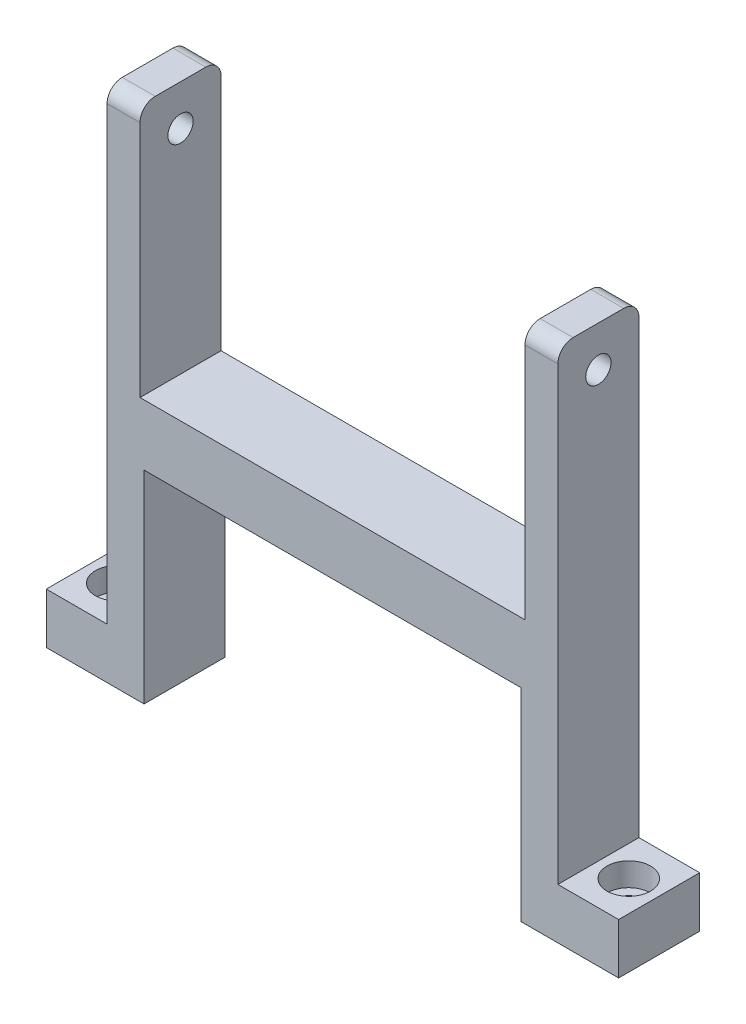
from build123d import *

# Parameters (mm, degrees)
SKETCH_1_W                = 44.5
SKETCH_1_H                = 51
EXTRUDE_1_DEPTH           = 8
SKETCH_2_W                = 38
SKETCH_2_H                = 25
CUT_EXTRUDE_1_DEPTH       = 9
MM_1_D                    = 2.5
FILLET_1_R                = 1.5
SKETCH_5_W                = 37.2
SKETCH_5_H                = 20
CUT_EXTRUDE_2_DEPTH       = 15
SKETCH_6_W                = 6
SKETCH_6_H                = 8
EXTRUDE_2_DEPTH           = 5
HOLE_WIZARD_2_D           = 2.4
HOLE_WIZARD_2_CBORE_D     = 4.3
HOLE_WIZARD_2_CBORE_DEPTH = 2.3


with BuildPart() as part:
    # 草图1 → 凸台-拉伸1 (new body)
    with BuildSketch(Plane.XY):
        Rectangle(SKETCH_1_W, SKETCH_1_H)
    extrude(amount=EXTRUDE_1_DEPTH)

    # 草图2 → 切除-拉伸1 (cut, through all)
    with BuildSketch(Plane.XY.offset(8)):
        with Locations((0, 13)):
            Rectangle(SKETCH_2_W, SKETCH_2_H)
    extrude(amount=-CUT_EXTRUDE_1_DEPTH, mode=Mode.SUBTRACT)

    # 大小mm 暗销孔1 (through all)
    with Locations(Plane.ZY.offset(22.25)):
        with Locations((4, 21.5)):
            Hole(MM_1_D / 2)

    # 圆角1
    fillet_1_edges = [part.edges().sort_by_distance(p)[0] for p in [
        (20.625, 25.5, 8),
        (-20.625, 25.5, 0),
        (-20.625, 25.5, 8),
        (20.625, 25.5, 0),
    ]]
    fillet(fillet_1_edges, radius=FILLET_1_R)

    # 草图5 → 切除-拉伸2 (cut)
    with BuildSketch(Plane(origin=(0, 0, 0), x_dir=(-1, 0, 0), z_dir=(0, 0, -1))):
        with Locations((0, -15.5)):
            Rectangle(SKETCH_5_W, SKETCH_5_H)
    extrude(amount=-CUT_EXTRUDE_2_DEPTH, mode=Mode.SUBTRACT)

    # 草图6 → 凸台-拉伸2 (add)
    with BuildSketch(Plane.XZ.offset(25.5)):
        with Locations((-25.25, 4)):
            Rectangle(SKETCH_6_W, SKETCH_6_H)
    extrude_2 = extrude(amount=-EXTRUDE_2_DEPTH)

    # 镜向1: 凸台-拉伸2 across plane
    add(extrude_2.mirror(Plane(origin=(0, 0, 0), x_dir=(0, 0, 1), z_dir=(1, 0, 0))))

    # 打孔尺寸(%根据)内六角圆柱头螺钉的类型2 (through all)
    with Locations(Plane(origin=(0, -20.5, 0), x_dir=(1, 0, 0), z_dir=(0, 1, 0))):
        with Locations((-25.25, -4)):
            hole_wizard_2 = CounterBoreHole(HOLE_WIZARD_2_D / 2, HOLE_WIZARD_2_CBORE_D / 2, HOLE_WIZARD_2_CBORE_DEPTH)

    # 镜向2: 打孔尺寸(%根据)内六角圆柱头螺钉的类型2 across plane
    add(hole_wizard_2.mirror(Plane(origin=(0, 0, 0), x_dir=(0, 0, 1), z_dir=(1, 0, 0))), mode=Mode.SUBTRACT)


solid = part.part
